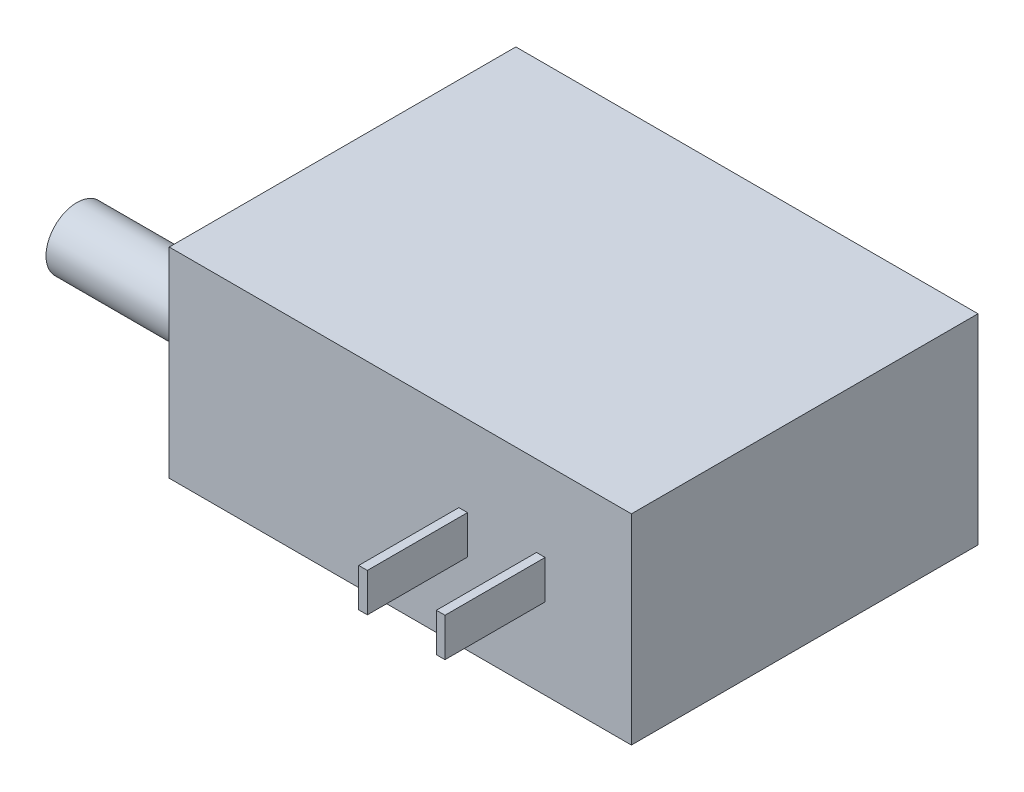
from build123d import *

# Parameters (mm, degrees)
SKETCH1_W           = 76.2
SKETCH1_H           = 57.15
BOSS_EXTRUDE1_DEPTH = 33.02
SKETCH2_R           = 5.08
BOSS_EXTRUDE2_DEPTH = 25.4
SKETCH3_W           = 1.4224
SKETCH3_H           = 6.35
BOSS_EXTRUDE3_DEPTH = 16.51


with BuildPart() as part:
    # Sketch1 → Boss-Extrude1 (new body)
    with BuildSketch(Plane(origin=(0, 0, 0), x_dir=(1, 0, 0), z_dir=(0, 1, 0))):
        Rectangle(SKETCH1_W, SKETCH1_H)
    extrude(amount=BOSS_EXTRUDE1_DEPTH)

    # Sketch2 → Boss-Extrude2 (add)
    with BuildSketch(Plane.ZY.offset(38.1)):
        with Locations((18.415, 16.51)):
            Circle(SKETCH2_R)
    extrude(amount=BOSS_EXTRUDE2_DEPTH)

    # Sketch3 → Boss-Extrude3 (add)
    with BuildSketch(Plane.XY.offset(28.575)):
        with Locations((23.1648, 16.51)):
            Rectangle(SKETCH3_W, SKETCH3_H)
        with Locations((10.3632, 16.51)):
            Rectangle(SKETCH3_W, SKETCH3_H)
    extrude(amount=BOSS_EXTRUDE3_DEPTH)


solid = part.part
